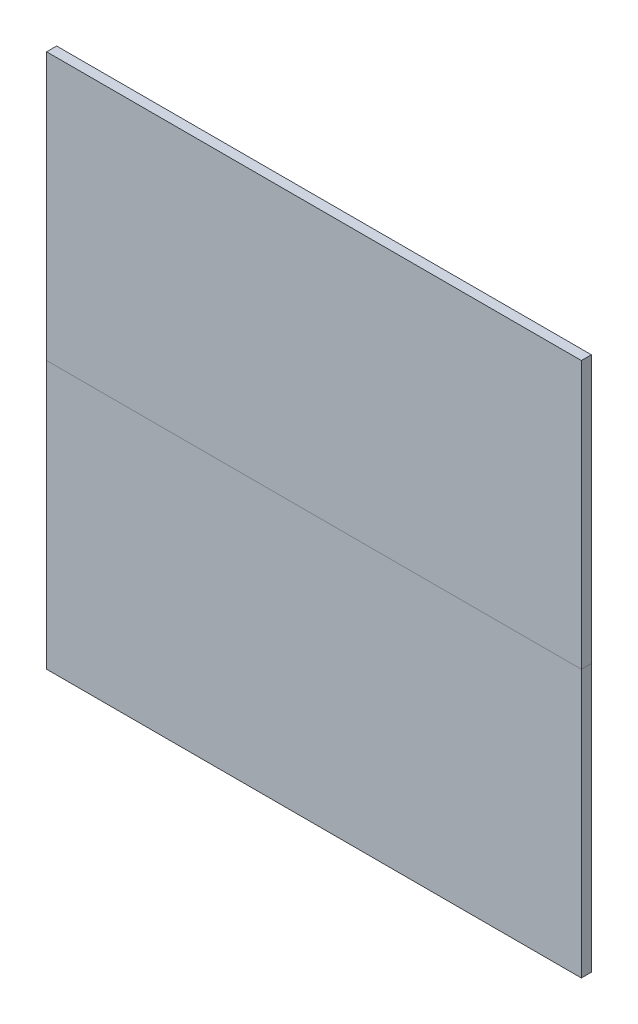
from build123d import *

# Parameters (mm, degrees)
CROQUIS1_W              = 16
CROQUIS1_H              = 8
SALIENTE_EXTRUIR1_DEPTH = 0.3
CROQUIS2_W              = 16
CROQUIS2_H              = 8
SALIENTE_EXTRUIR2_DEPTH = 0.3


with BuildPart() as part:
    # Croquis1 → Saliente-Extruir1 (new body)
    with BuildSketch(Plane.XY):
        with Locations((8, 4)):
            Rectangle(CROQUIS1_W, CROQUIS1_H)
    extrude(amount=SALIENTE_EXTRUIR1_DEPTH)


with BuildPart() as body_2:
    # Croquis2 → Saliente-Extruir2 (new body)
    with BuildSketch(Plane.XY.offset(0.3)):
        with Locations((8, 12)):
            Rectangle(CROQUIS2_W, CROQUIS2_H)
    extrude(amount=-SALIENTE_EXTRUIR2_DEPTH)


solid = Compound([part.part, body_2.part])
